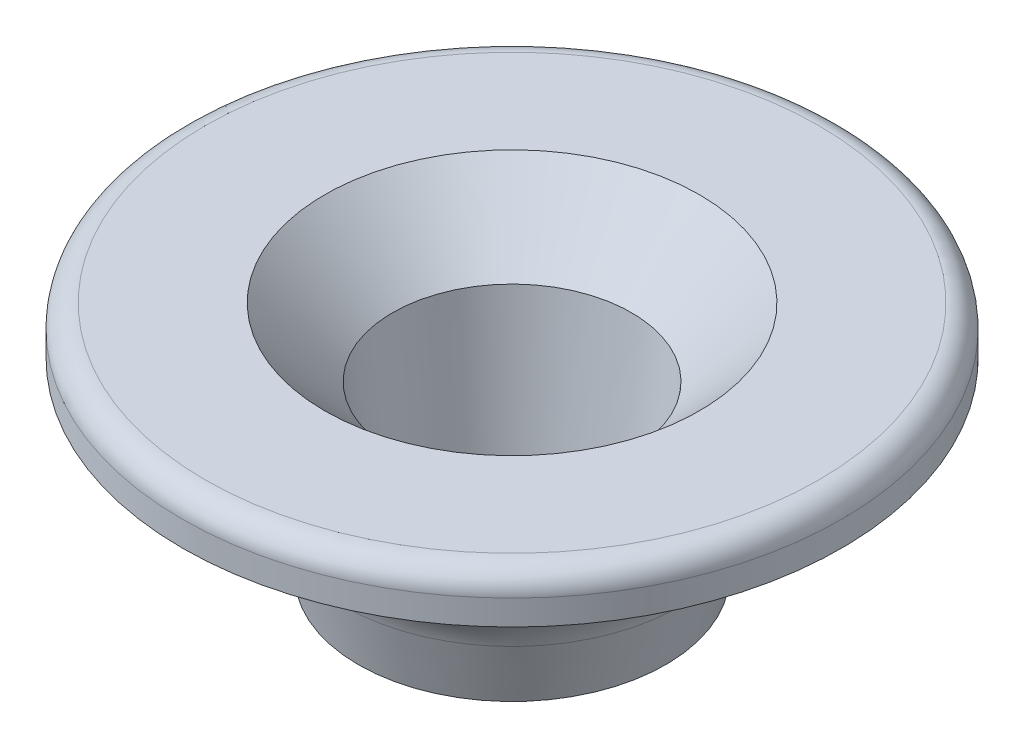
from build123d import *

# Parameters (mm, degrees)
CONG_1_R = 4
CONG_2_R = 0.5
CONG_4_R = 1


with BuildPart() as part:
    # Esquisse1 → Révolution1 (revolve)
    with BuildSketch(Plane.XY, mode=Mode.PRIVATE) as r_volution1_sk:
        Polygon((-8.23, 14.28840181), (-14.48, 14.28840181), (-14.48, 12.18840181), (-10.48, 12.18840181), (-10.48, 9.78840181), (-7.75, 7.88840181), (-6.75, 3.88840181), (-4.4, 3.88840181), (-5.25, 11.28840181), align=None)
    revolve(r_volution1_sk.sketch.rotate(Axis((0, 31.998542825, 0), (0, -1, 0)), 270), axis=Axis((0, 31.998542825, 0), (0, -1, 0)))  # turned: the seam where the file's is

    # Congé1
    cong_1_edges = [part.edges().sort_by_distance(p)[0] for p in [
        (0, 7.88840181, -7.75),
    ]]
    fillet(cong_1_edges, radius=CONG_1_R)

    # Congé2
    cong_2_edges = [part.edges().sort_by_distance(p)[0] for p in [
        (0, 3.88840181, -4.4),
    ]]
    fillet(cong_2_edges, radius=CONG_2_R)

    # Congé4
    cong_4_edges = [part.edges().sort_by_distance(p)[0] for p in [
        (0, 14.28840181, -14.48),
    ]]
    fillet(cong_4_edges, radius=CONG_4_R)


solid = part.part
